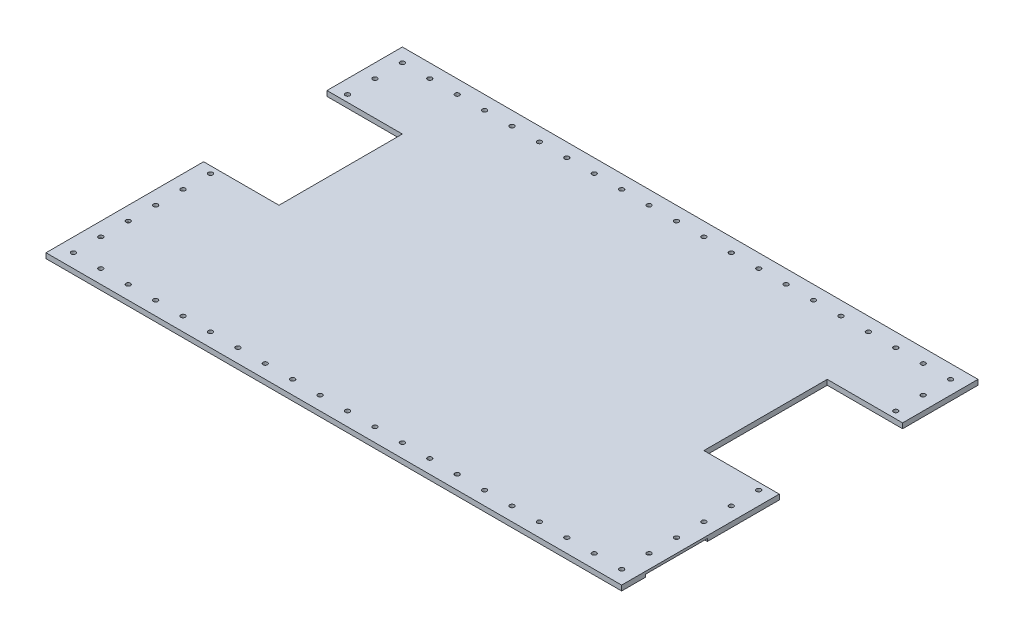
from build123d import *

# Parameters (mm, degrees)
SKETCH1_W                = 533.4
SKETCH1_H                = 330.2
BOSS_EXTRUDE1_DEPTH      = 4.7625
SKETCH2_R                = 2.0701
CUT_EXTRUDE1_DEPTH       = 5.7625
LPATTERN1_COUNT          = 23
LPATTERN1_PITCH          = 25.4
LPATTERN2_COUNT          = 32
LPATTERN2_PITCH          = 25.4
MIRROR2_COPY_1_SKETCH_R  = 2.0701
MIRROR2_COPY_1_DEPTH     = 5.7625
MIRROR2_COPY_2_SKETCH_R  = 2.0701
MIRROR2_COPY_2_DEPTH     = 5.7625
MIRROR2_COPY_3_SKETCH_R  = 2.0701
MIRROR2_COPY_3_DEPTH     = 5.7625
MIRROR2_COPY_4_SKETCH_R  = 2.0701
MIRROR2_COPY_4_DEPTH     = 5.7625
MIRROR2_COPY_5_SKETCH_R  = 2.0701
MIRROR2_COPY_5_DEPTH     = 5.7625
MIRROR2_COPY_6_SKETCH_R  = 2.0701
MIRROR2_COPY_6_DEPTH     = 5.7625
MIRROR2_COPY_7_SKETCH_R  = 2.0701
MIRROR2_COPY_7_DEPTH     = 5.7625
MIRROR2_COPY_8_SKETCH_R  = 2.0701
MIRROR2_COPY_8_DEPTH     = 5.7625
MIRROR2_COPY_9_SKETCH_R  = 2.0701
MIRROR2_COPY_9_DEPTH     = 5.7625
MIRROR2_COPY_10_SKETCH_R = 2.0701
MIRROR2_COPY_10_DEPTH    = 5.7625
MIRROR2_COPY_11_SKETCH_R = 2.0701
MIRROR2_COPY_11_DEPTH    = 5.7625
MIRROR2_COPY_12_SKETCH_R = 2.0701
MIRROR2_COPY_12_DEPTH    = 5.7625
MIRROR2_COPY_13_SKETCH_R = 2.0701
MIRROR2_COPY_13_DEPTH    = 5.7625
MIRROR2_COPY_14_SKETCH_R = 2.0701
MIRROR2_COPY_14_DEPTH    = 5.7625
MIRROR2_COPY_15_SKETCH_R = 2.0701
MIRROR2_COPY_15_DEPTH    = 5.7625
MIRROR2_COPY_16_SKETCH_R = 2.0701
MIRROR2_COPY_16_DEPTH    = 5.7625
MIRROR2_COPY_17_SKETCH_R = 2.0701
MIRROR2_COPY_17_DEPTH    = 5.7625
MIRROR2_COPY_18_SKETCH_R = 2.0701
MIRROR2_COPY_18_DEPTH    = 5.7625
MIRROR2_COPY_19_SKETCH_R = 2.0701
MIRROR2_COPY_19_DEPTH    = 5.7625
MIRROR2_COPY_20_SKETCH_R = 2.0701
MIRROR2_COPY_20_DEPTH    = 5.7625
MIRROR2_COPY_21_SKETCH_R = 2.0701
MIRROR2_COPY_21_DEPTH    = 5.7625
MIRROR2_COPY_22_SKETCH_R = 2.0701
MIRROR2_COPY_22_DEPTH    = 5.7625
MIRROR2_COPY_23_SKETCH_R = 2.0701
MIRROR2_COPY_23_DEPTH    = 5.7625
MIRROR2_COPY_24_SKETCH_R = 2.0701
MIRROR2_COPY_24_DEPTH    = 5.7625
MIRROR2_COPY_25_SKETCH_R = 2.0701
MIRROR2_COPY_25_DEPTH    = 5.7625
MIRROR2_COPY_26_SKETCH_R = 2.0701
MIRROR2_COPY_26_DEPTH    = 5.7625
MIRROR2_COPY_27_SKETCH_R = 2.0701
MIRROR2_COPY_27_DEPTH    = 5.7625
MIRROR2_COPY_28_SKETCH_R = 2.0701
MIRROR2_COPY_28_DEPTH    = 5.7625
MIRROR2_COPY_29_SKETCH_R = 2.0701
MIRROR2_COPY_29_DEPTH    = 5.7625
MIRROR2_COPY_30_SKETCH_R = 2.0701
MIRROR2_COPY_30_DEPTH    = 5.7625
MIRROR2_COPY_31_SKETCH_R = 2.0701
MIRROR2_COPY_31_DEPTH    = 5.7625
MIRROR2_COPY_32_SKETCH_R = 2.0701
MIRROR2_COPY_32_DEPTH    = 5.7625
MIRROR3_COPY_1_SKETCH_R  = 2.0701
MIRROR3_COPY_1_DEPTH     = 5.7625
MIRROR3_COPY_2_SKETCH_R  = 2.0701
MIRROR3_COPY_2_DEPTH     = 5.7625
MIRROR3_COPY_3_SKETCH_R  = 2.0701
MIRROR3_COPY_3_DEPTH     = 5.7625
MIRROR3_COPY_4_SKETCH_R  = 2.0701
MIRROR3_COPY_4_DEPTH     = 5.7625
MIRROR3_COPY_5_SKETCH_R  = 2.0701
MIRROR3_COPY_5_DEPTH     = 5.7625
MIRROR3_COPY_6_SKETCH_R  = 2.0701
MIRROR3_COPY_6_DEPTH     = 5.7625
MIRROR3_COPY_7_SKETCH_R  = 2.0701
MIRROR3_COPY_7_DEPTH     = 5.7625
MIRROR3_COPY_8_SKETCH_R  = 2.0701
MIRROR3_COPY_8_DEPTH     = 5.7625
MIRROR3_COPY_9_SKETCH_R  = 2.0701
MIRROR3_COPY_9_DEPTH     = 5.7625
MIRROR3_COPY_10_SKETCH_R = 2.0701
MIRROR3_COPY_10_DEPTH    = 5.7625
MIRROR3_COPY_11_SKETCH_R = 2.0701
MIRROR3_COPY_11_DEPTH    = 5.7625
MIRROR3_COPY_12_SKETCH_R = 2.0701
MIRROR3_COPY_12_DEPTH    = 5.7625
MIRROR3_COPY_13_SKETCH_R = 2.0701
MIRROR3_COPY_13_DEPTH    = 5.7625
MIRROR3_COPY_14_SKETCH_R = 2.0701
MIRROR3_COPY_14_DEPTH    = 5.7625
MIRROR3_COPY_15_SKETCH_R = 2.0701
MIRROR3_COPY_15_DEPTH    = 5.7625
MIRROR3_COPY_16_SKETCH_R = 2.0701
MIRROR3_COPY_16_DEPTH    = 5.7625
MIRROR3_COPY_17_SKETCH_R = 2.0701
MIRROR3_COPY_17_DEPTH    = 5.7625
MIRROR3_COPY_18_SKETCH_R = 2.0701
MIRROR3_COPY_18_DEPTH    = 5.7625
MIRROR3_COPY_19_SKETCH_R = 2.0701
MIRROR3_COPY_19_DEPTH    = 5.7625
MIRROR3_COPY_20_SKETCH_R = 2.0701
MIRROR3_COPY_20_DEPTH    = 5.7625
MIRROR3_COPY_21_SKETCH_R = 2.0701
MIRROR3_COPY_21_DEPTH    = 5.7625
MIRROR3_COPY_22_SKETCH_R = 2.0701
MIRROR3_COPY_22_DEPTH    = 5.7625
MIRROR3_COPY_23_SKETCH_R = 2.0701
MIRROR3_COPY_23_DEPTH    = 5.7625
CUT_EXTRUDE2_DEPTH       = 2.38125
SKETCH4_W                = 69.85
SKETCH4_H                = 114.3
CUT_EXTRUDE3_DEPTH       = 5.7625


with BuildPart() as part:
    # Sketch1 → Boss-Extrude1 (new body)
    with BuildSketch(Plane(origin=(0, 0, 0), x_dir=(1, 0, 0), z_dir=(0, 1, 0))):
        Rectangle(SKETCH1_W, SKETCH1_H)
    extrude(amount=BOSS_EXTRUDE1_DEPTH)

    # Sketch2 → Cut-Extrude1 (cut, through all)
    with BuildSketch(Plane(origin=(0, 4.7625, 0), x_dir=(1, 0, 0), z_dir=(0, 1, 0))):
        with Locations((-254, -152.4)):
            Circle(SKETCH2_R)
    cut_extrude1 = extrude(amount=-CUT_EXTRUDE1_DEPTH, mode=Mode.SUBTRACT)

    # LPattern1: Cut-Extrude1 ×23
    with Locations(*[(i * LPATTERN1_PITCH, 0, 0) for i in range(1, LPATTERN1_COUNT)]):
        add(cut_extrude1, mode=Mode.SUBTRACT)

    # LPattern2: Cut-Extrude1 ×32
    with Locations(*[(0, 0, -i * LPATTERN2_PITCH) for i in range(1, LPATTERN2_COUNT)]):
        add(cut_extrude1, mode=Mode.SUBTRACT)

    # Mirror2 copy 1 sketch → Mirror2 copy 1 (cut, through all)
    with BuildSketch(Plane(origin=(0, 4.7625, -25.4), x_dir=(-1, 0, 0), z_dir=(0, 1, 0))):
        with Locations((-254, 152.4)):
            Circle(MIRROR2_COPY_1_SKETCH_R)
    extrude(amount=-MIRROR2_COPY_1_DEPTH, mode=Mode.SUBTRACT)

    # Mirror2 copy 2 sketch → Mirror2 copy 2 (cut, through all)
    with BuildSketch(Plane(origin=(0, 4.7625, -50.8), x_dir=(-1, 0, 0), z_dir=(0, 1, 0))):
        with Locations((-254, 152.4)):
            Circle(MIRROR2_COPY_2_SKETCH_R)
    extrude(amount=-MIRROR2_COPY_2_DEPTH, mode=Mode.SUBTRACT)

    # Mirror2 copy 3 sketch → Mirror2 copy 3 (cut, through all)
    with BuildSketch(Plane(origin=(0, 4.7625, -76.2), x_dir=(-1, 0, 0), z_dir=(0, 1, 0))):
        with Locations((-254, 152.4)):
            Circle(MIRROR2_COPY_3_SKETCH_R)
    extrude(amount=-MIRROR2_COPY_3_DEPTH, mode=Mode.SUBTRACT)

    # Mirror2 copy 4 sketch → Mirror2 copy 4 (cut, through all)
    with BuildSketch(Plane(origin=(0, 4.7625, -101.6), x_dir=(-1, 0, 0), z_dir=(0, 1, 0))):
        with Locations((-254, 152.4)):
            Circle(MIRROR2_COPY_4_SKETCH_R)
    extrude(amount=-MIRROR2_COPY_4_DEPTH, mode=Mode.SUBTRACT)

    # Mirror2 copy 5 sketch → Mirror2 copy 5 (cut, through all)
    with BuildSketch(Plane(origin=(0, 4.7625, -127), x_dir=(-1, 0, 0), z_dir=(0, 1, 0))):
        with Locations((-254, 152.4)):
            Circle(MIRROR2_COPY_5_SKETCH_R)
    extrude(amount=-MIRROR2_COPY_5_DEPTH, mode=Mode.SUBTRACT)

    # Mirror2 copy 6 sketch → Mirror2 copy 6 (cut, through all)
    with BuildSketch(Plane(origin=(0, 4.7625, -152.4), x_dir=(-1, 0, 0), z_dir=(0, 1, 0))):
        with Locations((-254, 152.4)):
            Circle(MIRROR2_COPY_6_SKETCH_R)
    extrude(amount=-MIRROR2_COPY_6_DEPTH, mode=Mode.SUBTRACT)

    # Mirror2 copy 7 sketch → Mirror2 copy 7 (cut, through all)
    with BuildSketch(Plane(origin=(0, 4.7625, -177.8), x_dir=(-1, 0, 0), z_dir=(0, 1, 0))):
        with Locations((-254, 152.4)):
            Circle(MIRROR2_COPY_7_SKETCH_R)
    extrude(amount=-MIRROR2_COPY_7_DEPTH, mode=Mode.SUBTRACT)

    # Mirror2 copy 8 sketch → Mirror2 copy 8 (cut, through all)
    with BuildSketch(Plane(origin=(0, 4.7625, -203.2), x_dir=(-1, 0, 0), z_dir=(0, 1, 0))):
        with Locations((-254, 152.4)):
            Circle(MIRROR2_COPY_8_SKETCH_R)
    extrude(amount=-MIRROR2_COPY_8_DEPTH, mode=Mode.SUBTRACT)

    # Mirror2 copy 9 sketch → Mirror2 copy 9 (cut, through all)
    with BuildSketch(Plane(origin=(0, 4.7625, -228.6), x_dir=(-1, 0, 0), z_dir=(0, 1, 0))):
        with Locations((-254, 152.4)):
            Circle(MIRROR2_COPY_9_SKETCH_R)
    extrude(amount=-MIRROR2_COPY_9_DEPTH, mode=Mode.SUBTRACT)

    # Mirror2 copy 10 sketch → Mirror2 copy 10 (cut, through all)
    with BuildSketch(Plane(origin=(0, 4.7625, -254), x_dir=(-1, 0, 0), z_dir=(0, 1, 0))):
        with Locations((-254, 152.4)):
            Circle(MIRROR2_COPY_10_SKETCH_R)
    extrude(amount=-MIRROR2_COPY_10_DEPTH, mode=Mode.SUBTRACT)

    # Mirror2 copy 11 sketch → Mirror2 copy 11 (cut, through all)
    with BuildSketch(Plane(origin=(0, 4.7625, -279.4), x_dir=(-1, 0, 0), z_dir=(0, 1, 0))):
        with Locations((-254, 152.4)):
            Circle(MIRROR2_COPY_11_SKETCH_R)
    extrude(amount=-MIRROR2_COPY_11_DEPTH, mode=Mode.SUBTRACT)

    # Mirror2 copy 12 sketch → Mirror2 copy 12 (cut, through all)
    with BuildSketch(Plane(origin=(0, 4.7625, -304.8), x_dir=(-1, 0, 0), z_dir=(0, 1, 0))):
        with Locations((-254, 152.4)):
            Circle(MIRROR2_COPY_12_SKETCH_R)
    extrude(amount=-MIRROR2_COPY_12_DEPTH, mode=Mode.SUBTRACT)

    # Mirror2 copy 13 sketch → Mirror2 copy 13 (cut, through all)
    with BuildSketch(Plane(origin=(0, 4.7625, -330.2), x_dir=(-1, 0, 0), z_dir=(0, 1, 0))):
        with Locations((-254, 152.4)):
            Circle(MIRROR2_COPY_13_SKETCH_R)
    extrude(amount=-MIRROR2_COPY_13_DEPTH, mode=Mode.SUBTRACT)

    # Mirror2 copy 14 sketch → Mirror2 copy 14 (cut, through all)
    with BuildSketch(Plane(origin=(0, 4.7625, -355.6), x_dir=(-1, 0, 0), z_dir=(0, 1, 0))):
        with Locations((-254, 152.4)):
            Circle(MIRROR2_COPY_14_SKETCH_R)
    extrude(amount=-MIRROR2_COPY_14_DEPTH, mode=Mode.SUBTRACT)

    # Mirror2 copy 15 sketch → Mirror2 copy 15 (cut, through all)
    with BuildSketch(Plane(origin=(0, 4.7625, -381), x_dir=(-1, 0, 0), z_dir=(0, 1, 0))):
        with Locations((-254, 152.4)):
            Circle(MIRROR2_COPY_15_SKETCH_R)
    extrude(amount=-MIRROR2_COPY_15_DEPTH, mode=Mode.SUBTRACT)

    # Mirror2 copy 16 sketch → Mirror2 copy 16 (cut, through all)
    with BuildSketch(Plane(origin=(0, 4.7625, -406.4), x_dir=(-1, 0, 0), z_dir=(0, 1, 0))):
        with Locations((-254, 152.4)):
            Circle(MIRROR2_COPY_16_SKETCH_R)
    extrude(amount=-MIRROR2_COPY_16_DEPTH, mode=Mode.SUBTRACT)

    # Mirror2 copy 17 sketch → Mirror2 copy 17 (cut, through all)
    with BuildSketch(Plane(origin=(0, 4.7625, -431.8), x_dir=(-1, 0, 0), z_dir=(0, 1, 0))):
        with Locations((-254, 152.4)):
            Circle(MIRROR2_COPY_17_SKETCH_R)
    extrude(amount=-MIRROR2_COPY_17_DEPTH, mode=Mode.SUBTRACT)

    # Mirror2 copy 18 sketch → Mirror2 copy 18 (cut, through all)
    with BuildSketch(Plane(origin=(0, 4.7625, -457.2), x_dir=(-1, 0, 0), z_dir=(0, 1, 0))):
        with Locations((-254, 152.4)):
            Circle(MIRROR2_COPY_18_SKETCH_R)
    extrude(amount=-MIRROR2_COPY_18_DEPTH, mode=Mode.SUBTRACT)

    # Mirror2 copy 19 sketch → Mirror2 copy 19 (cut, through all)
    with BuildSketch(Plane(origin=(0, 4.7625, -482.6), x_dir=(-1, 0, 0), z_dir=(0, 1, 0))):
        with Locations((-254, 152.4)):
            Circle(MIRROR2_COPY_19_SKETCH_R)
    extrude(amount=-MIRROR2_COPY_19_DEPTH, mode=Mode.SUBTRACT)

    # Mirror2 copy 20 sketch → Mirror2 copy 20 (cut, through all)
    with BuildSketch(Plane(origin=(0, 4.7625, -508), x_dir=(-1, 0, 0), z_dir=(0, 1, 0))):
        with Locations((-254, 152.4)):
            Circle(MIRROR2_COPY_20_SKETCH_R)
    extrude(amount=-MIRROR2_COPY_20_DEPTH, mode=Mode.SUBTRACT)

    # Mirror2 copy 21 sketch → Mirror2 copy 21 (cut, through all)
    with BuildSketch(Plane(origin=(0, 4.7625, -533.4), x_dir=(-1, 0, 0), z_dir=(0, 1, 0))):
        with Locations((-254, 152.4)):
            Circle(MIRROR2_COPY_21_SKETCH_R)
    extrude(amount=-MIRROR2_COPY_21_DEPTH, mode=Mode.SUBTRACT)

    # Mirror2 copy 22 sketch → Mirror2 copy 22 (cut, through all)
    with BuildSketch(Plane(origin=(0, 4.7625, -558.8), x_dir=(-1, 0, 0), z_dir=(0, 1, 0))):
        with Locations((-254, 152.4)):
            Circle(MIRROR2_COPY_22_SKETCH_R)
    extrude(amount=-MIRROR2_COPY_22_DEPTH, mode=Mode.SUBTRACT)

    # Mirror2 copy 23 sketch → Mirror2 copy 23 (cut, through all)
    with BuildSketch(Plane(origin=(0, 4.7625, -584.2), x_dir=(-1, 0, 0), z_dir=(0, 1, 0))):
        with Locations((-254, 152.4)):
            Circle(MIRROR2_COPY_23_SKETCH_R)
    extrude(amount=-MIRROR2_COPY_23_DEPTH, mode=Mode.SUBTRACT)

    # Mirror2 copy 24 sketch → Mirror2 copy 24 (cut, through all)
    with BuildSketch(Plane(origin=(0, 4.7625, -609.6), x_dir=(-1, 0, 0), z_dir=(0, 1, 0))):
        with Locations((-254, 152.4)):
            Circle(MIRROR2_COPY_24_SKETCH_R)
    extrude(amount=-MIRROR2_COPY_24_DEPTH, mode=Mode.SUBTRACT)

    # Mirror2 copy 25 sketch → Mirror2 copy 25 (cut, through all)
    with BuildSketch(Plane(origin=(0, 4.7625, -635), x_dir=(-1, 0, 0), z_dir=(0, 1, 0))):
        with Locations((-254, 152.4)):
            Circle(MIRROR2_COPY_25_SKETCH_R)
    extrude(amount=-MIRROR2_COPY_25_DEPTH, mode=Mode.SUBTRACT)

    # Mirror2 copy 26 sketch → Mirror2 copy 26 (cut, through all)
    with BuildSketch(Plane(origin=(0, 4.7625, -660.4), x_dir=(-1, 0, 0), z_dir=(0, 1, 0))):
        with Locations((-254, 152.4)):
            Circle(MIRROR2_COPY_26_SKETCH_R)
    extrude(amount=-MIRROR2_COPY_26_DEPTH, mode=Mode.SUBTRACT)

    # Mirror2 copy 27 sketch → Mirror2 copy 27 (cut, through all)
    with BuildSketch(Plane(origin=(0, 4.7625, -685.8), x_dir=(-1, 0, 0), z_dir=(0, 1, 0))):
        with Locations((-254, 152.4)):
            Circle(MIRROR2_COPY_27_SKETCH_R)
    extrude(amount=-MIRROR2_COPY_27_DEPTH, mode=Mode.SUBTRACT)

    # Mirror2 copy 28 sketch → Mirror2 copy 28 (cut, through all)
    with BuildSketch(Plane(origin=(0, 4.7625, -711.2), x_dir=(-1, 0, 0), z_dir=(0, 1, 0))):
        with Locations((-254, 152.4)):
            Circle(MIRROR2_COPY_28_SKETCH_R)
    extrude(amount=-MIRROR2_COPY_28_DEPTH, mode=Mode.SUBTRACT)

    # Mirror2 copy 29 sketch → Mirror2 copy 29 (cut, through all)
    with BuildSketch(Plane(origin=(0, 4.7625, -736.6), x_dir=(-1, 0, 0), z_dir=(0, 1, 0))):
        with Locations((-254, 152.4)):
            Circle(MIRROR2_COPY_29_SKETCH_R)
    extrude(amount=-MIRROR2_COPY_29_DEPTH, mode=Mode.SUBTRACT)

    # Mirror2 copy 30 sketch → Mirror2 copy 30 (cut, through all)
    with BuildSketch(Plane(origin=(0, 4.7625, -762), x_dir=(-1, 0, 0), z_dir=(0, 1, 0))):
        with Locations((-254, 152.4)):
            Circle(MIRROR2_COPY_30_SKETCH_R)
    extrude(amount=-MIRROR2_COPY_30_DEPTH, mode=Mode.SUBTRACT)

    # Mirror2 copy 31 sketch → Mirror2 copy 31 (cut, through all)
    with BuildSketch(Plane(origin=(0, 4.7625, -787.4), x_dir=(-1, 0, 0), z_dir=(0, 1, 0))):
        with Locations((-254, 152.4)):
            Circle(MIRROR2_COPY_31_SKETCH_R)
    extrude(amount=-MIRROR2_COPY_31_DEPTH, mode=Mode.SUBTRACT)

    # Mirror2 copy 32 sketch → Mirror2 copy 32 (cut, through all)
    with BuildSketch(Plane(origin=(0, 4.7625, 0), x_dir=(-1, 0, 0), z_dir=(0, 1, 0))):
        with Locations((-254, 152.4)):
            Circle(MIRROR2_COPY_32_SKETCH_R)
    extrude(amount=-MIRROR2_COPY_32_DEPTH, mode=Mode.SUBTRACT)

    # Mirror3 copy 1 sketch → Mirror3 copy 1 (cut, through all)
    with BuildSketch(Plane(origin=(25.4, 4.7625, 0), x_dir=(1, 0, 0), z_dir=(0, 1, 0))):
        with Locations((-254, 152.4)):
            Circle(MIRROR3_COPY_1_SKETCH_R)
    extrude(amount=-MIRROR3_COPY_1_DEPTH, mode=Mode.SUBTRACT)

    # Mirror3 copy 2 sketch → Mirror3 copy 2 (cut, through all)
    with BuildSketch(Plane(origin=(50.8, 4.7625, 0), x_dir=(1, 0, 0), z_dir=(0, 1, 0))):
        with Locations((-254, 152.4)):
            Circle(MIRROR3_COPY_2_SKETCH_R)
    extrude(amount=-MIRROR3_COPY_2_DEPTH, mode=Mode.SUBTRACT)

    # Mirror3 copy 3 sketch → Mirror3 copy 3 (cut, through all)
    with BuildSketch(Plane(origin=(76.2, 4.7625, 0), x_dir=(1, 0, 0), z_dir=(0, 1, 0))):
        with Locations((-254, 152.4)):
            Circle(MIRROR3_COPY_3_SKETCH_R)
    extrude(amount=-MIRROR3_COPY_3_DEPTH, mode=Mode.SUBTRACT)

    # Mirror3 copy 4 sketch → Mirror3 copy 4 (cut, through all)
    with BuildSketch(Plane(origin=(101.6, 4.7625, 0), x_dir=(1, 0, 0), z_dir=(0, 1, 0))):
        with Locations((-254, 152.4)):
            Circle(MIRROR3_COPY_4_SKETCH_R)
    extrude(amount=-MIRROR3_COPY_4_DEPTH, mode=Mode.SUBTRACT)

    # Mirror3 copy 5 sketch → Mirror3 copy 5 (cut, through all)
    with BuildSketch(Plane(origin=(127, 4.7625, 0), x_dir=(1, 0, 0), z_dir=(0, 1, 0))):
        with Locations((-254, 152.4)):
            Circle(MIRROR3_COPY_5_SKETCH_R)
    extrude(amount=-MIRROR3_COPY_5_DEPTH, mode=Mode.SUBTRACT)

    # Mirror3 copy 6 sketch → Mirror3 copy 6 (cut, through all)
    with BuildSketch(Plane(origin=(152.4, 4.7625, 0), x_dir=(1, 0, 0), z_dir=(0, 1, 0))):
        with Locations((-254, 152.4)):
            Circle(MIRROR3_COPY_6_SKETCH_R)
    extrude(amount=-MIRROR3_COPY_6_DEPTH, mode=Mode.SUBTRACT)

    # Mirror3 copy 7 sketch → Mirror3 copy 7 (cut, through all)
    with BuildSketch(Plane(origin=(177.8, 4.7625, 0), x_dir=(1, 0, 0), z_dir=(0, 1, 0))):
        with Locations((-254, 152.4)):
            Circle(MIRROR3_COPY_7_SKETCH_R)
    extrude(amount=-MIRROR3_COPY_7_DEPTH, mode=Mode.SUBTRACT)

    # Mirror3 copy 8 sketch → Mirror3 copy 8 (cut, through all)
    with BuildSketch(Plane(origin=(203.2, 4.7625, 0), x_dir=(1, 0, 0), z_dir=(0, 1, 0))):
        with Locations((-254, 152.4)):
            Circle(MIRROR3_COPY_8_SKETCH_R)
    extrude(amount=-MIRROR3_COPY_8_DEPTH, mode=Mode.SUBTRACT)

    # Mirror3 copy 9 sketch → Mirror3 copy 9 (cut, through all)
    with BuildSketch(Plane(origin=(228.6, 4.7625, 0), x_dir=(1, 0, 0), z_dir=(0, 1, 0))):
        with Locations((-254, 152.4)):
            Circle(MIRROR3_COPY_9_SKETCH_R)
    extrude(amount=-MIRROR3_COPY_9_DEPTH, mode=Mode.SUBTRACT)

    # Mirror3 copy 10 sketch → Mirror3 copy 10 (cut, through all)
    with BuildSketch(Plane(origin=(254, 4.7625, 0), x_dir=(1, 0, 0), z_dir=(0, 1, 0))):
        with Locations((-254, 152.4)):
            Circle(MIRROR3_COPY_10_SKETCH_R)
    extrude(amount=-MIRROR3_COPY_10_DEPTH, mode=Mode.SUBTRACT)

    # Mirror3 copy 11 sketch → Mirror3 copy 11 (cut, through all)
    with BuildSketch(Plane(origin=(279.4, 4.7625, 0), x_dir=(1, 0, 0), z_dir=(0, 1, 0))):
        with Locations((-254, 152.4)):
            Circle(MIRROR3_COPY_11_SKETCH_R)
    extrude(amount=-MIRROR3_COPY_11_DEPTH, mode=Mode.SUBTRACT)

    # Mirror3 copy 12 sketch → Mirror3 copy 12 (cut, through all)
    with BuildSketch(Plane(origin=(304.8, 4.7625, 0), x_dir=(1, 0, 0), z_dir=(0, 1, 0))):
        with Locations((-254, 152.4)):
            Circle(MIRROR3_COPY_12_SKETCH_R)
    extrude(amount=-MIRROR3_COPY_12_DEPTH, mode=Mode.SUBTRACT)

    # Mirror3 copy 13 sketch → Mirror3 copy 13 (cut, through all)
    with BuildSketch(Plane(origin=(330.2, 4.7625, 0), x_dir=(1, 0, 0), z_dir=(0, 1, 0))):
        with Locations((-254, 152.4)):
            Circle(MIRROR3_COPY_13_SKETCH_R)
    extrude(amount=-MIRROR3_COPY_13_DEPTH, mode=Mode.SUBTRACT)

    # Mirror3 copy 14 sketch → Mirror3 copy 14 (cut, through all)
    with BuildSketch(Plane(origin=(355.6, 4.7625, 0), x_dir=(1, 0, 0), z_dir=(0, 1, 0))):
        with Locations((-254, 152.4)):
            Circle(MIRROR3_COPY_14_SKETCH_R)
    extrude(amount=-MIRROR3_COPY_14_DEPTH, mode=Mode.SUBTRACT)

    # Mirror3 copy 15 sketch → Mirror3 copy 15 (cut, through all)
    with BuildSketch(Plane(origin=(381, 4.7625, 0), x_dir=(1, 0, 0), z_dir=(0, 1, 0))):
        with Locations((-254, 152.4)):
            Circle(MIRROR3_COPY_15_SKETCH_R)
    extrude(amount=-MIRROR3_COPY_15_DEPTH, mode=Mode.SUBTRACT)

    # Mirror3 copy 16 sketch → Mirror3 copy 16 (cut, through all)
    with BuildSketch(Plane(origin=(406.4, 4.7625, 0), x_dir=(1, 0, 0), z_dir=(0, 1, 0))):
        with Locations((-254, 152.4)):
            Circle(MIRROR3_COPY_16_SKETCH_R)
    extrude(amount=-MIRROR3_COPY_16_DEPTH, mode=Mode.SUBTRACT)

    # Mirror3 copy 17 sketch → Mirror3 copy 17 (cut, through all)
    with BuildSketch(Plane(origin=(431.8, 4.7625, 0), x_dir=(1, 0, 0), z_dir=(0, 1, 0))):
        with Locations((-254, 152.4)):
            Circle(MIRROR3_COPY_17_SKETCH_R)
    extrude(amount=-MIRROR3_COPY_17_DEPTH, mode=Mode.SUBTRACT)

    # Mirror3 copy 18 sketch → Mirror3 copy 18 (cut, through all)
    with BuildSketch(Plane(origin=(457.2, 4.7625, 0), x_dir=(1, 0, 0), z_dir=(0, 1, 0))):
        with Locations((-254, 152.4)):
            Circle(MIRROR3_COPY_18_SKETCH_R)
    extrude(amount=-MIRROR3_COPY_18_DEPTH, mode=Mode.SUBTRACT)

    # Mirror3 copy 19 sketch → Mirror3 copy 19 (cut, through all)
    with BuildSketch(Plane(origin=(482.6, 4.7625, 0), x_dir=(1, 0, 0), z_dir=(0, 1, 0))):
        with Locations((-254, 152.4)):
            Circle(MIRROR3_COPY_19_SKETCH_R)
    extrude(amount=-MIRROR3_COPY_19_DEPTH, mode=Mode.SUBTRACT)

    # Mirror3 copy 20 sketch → Mirror3 copy 20 (cut, through all)
    with BuildSketch(Plane(origin=(508, 4.7625, 0), x_dir=(1, 0, 0), z_dir=(0, 1, 0))):
        with Locations((-254, 152.4)):
            Circle(MIRROR3_COPY_20_SKETCH_R)
    extrude(amount=-MIRROR3_COPY_20_DEPTH, mode=Mode.SUBTRACT)

    # Mirror3 copy 21 sketch → Mirror3 copy 21 (cut, through all)
    with BuildSketch(Plane(origin=(533.4, 4.7625, 0), x_dir=(1, 0, 0), z_dir=(0, 1, 0))):
        with Locations((-254, 152.4)):
            Circle(MIRROR3_COPY_21_SKETCH_R)
    extrude(amount=-MIRROR3_COPY_21_DEPTH, mode=Mode.SUBTRACT)

    # Mirror3 copy 22 sketch → Mirror3 copy 22 (cut, through all)
    with BuildSketch(Plane(origin=(558.8, 4.7625, 0), x_dir=(1, 0, 0), z_dir=(0, 1, 0))):
        with Locations((-254, 152.4)):
            Circle(MIRROR3_COPY_22_SKETCH_R)
    extrude(amount=-MIRROR3_COPY_22_DEPTH, mode=Mode.SUBTRACT)

    # Mirror3 copy 23 sketch → Mirror3 copy 23 (cut, through all)
    with BuildSketch(Plane(origin=(0, 4.7625, 0), x_dir=(1, 0, 0), z_dir=(0, 1, 0))):
        with Locations((-254, 152.4)):
            Circle(MIRROR3_COPY_23_SKETCH_R)
    extrude(amount=-MIRROR3_COPY_23_DEPTH, mode=Mode.SUBTRACT)

    # Sketch3 → Cut-Extrude2 (cut)
    with BuildSketch(Plane.XZ):
        with BuildLine():
            Line((-266.7, 142.875), (-241.3, 142.875))
            ThreePointArc((-241.3, 142.875), (-239.05493597, 141.94506403), (-238.125, 139.7))
            Line((-238.125, 139.7), (-238.125, 88.9))
            ThreePointArc((-238.125, 88.9), (-239.05493597, 86.65493597), (-241.3, 85.725))
            Line((-241.3, 85.725), (-266.7, 85.725))
            Line((-266.7, 85.725), (-266.7, 142.875))
        make_face()
        with BuildLine():
            Line((266.7, 85.725), (241.3, 85.725))
            ThreePointArc((241.3, 85.725), (239.05493597, 86.65493597), (238.125, 88.9))
            Line((238.125, 88.9), (238.125, 139.7))
            ThreePointArc((238.125, 139.7), (239.05493597, 141.94506403), (241.3, 142.875))
            Line((241.3, 142.875), (266.7, 142.875))
            Line((266.7, 142.875), (266.7, 85.725))
        make_face()
    extrude(amount=-CUT_EXTRUDE2_DEPTH, mode=Mode.SUBTRACT)

    # Sketch4 → Cut-Extrude3 (cut, through all)
    with BuildSketch(Plane(origin=(0, 4.7625, 0), x_dir=(1, 0, 0), z_dir=(0, 1, 0))):
        with Locations((231.775, 38.1)):
            Rectangle(SKETCH4_W, SKETCH4_H)
        with Locations((-231.775, 38.1)):
            Rectangle(SKETCH4_W, SKETCH4_H)
    extrude(amount=-CUT_EXTRUDE3_DEPTH, mode=Mode.SUBTRACT)


solid = part.part
